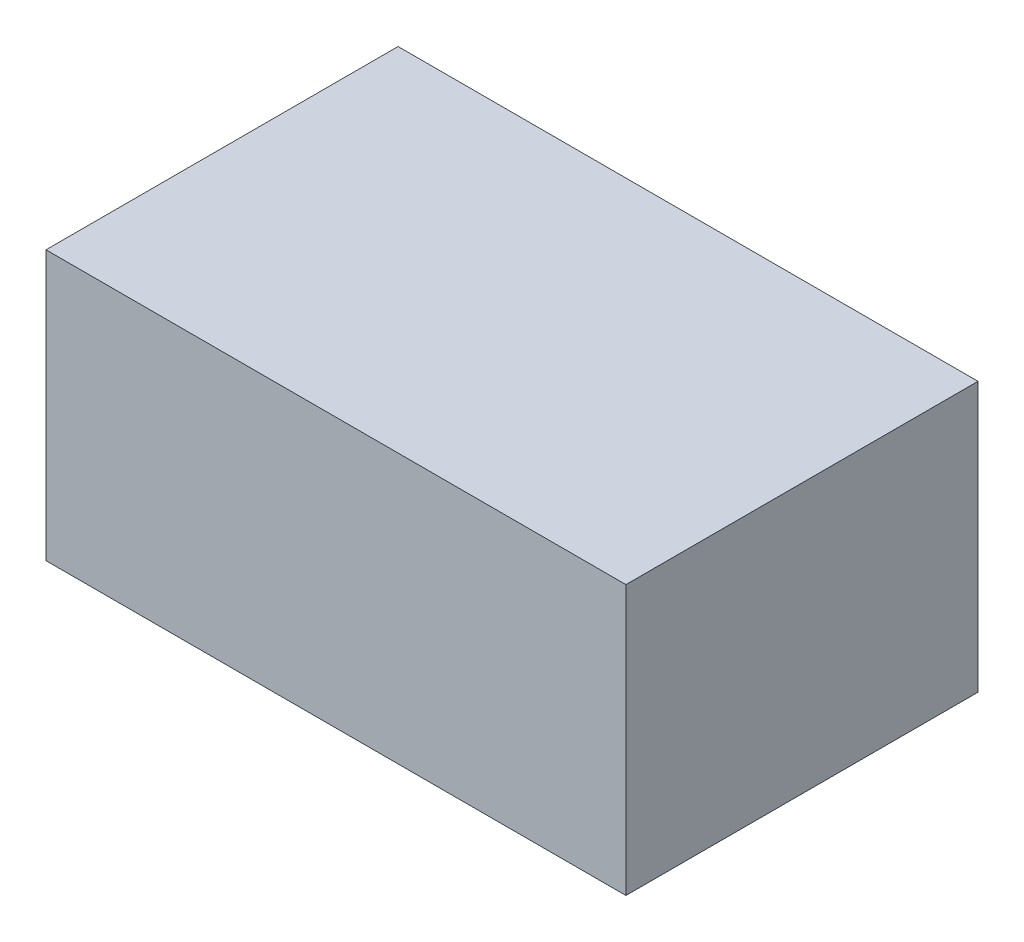
from build123d import *

# Parameters (mm, degrees)
SKETCH1_W           = 71.12
SKETCH1_H           = 43.18
BOSS_EXTRUDE1_DEPTH = 16.51


with BuildPart() as part:
    # Sketch1 → Boss-Extrude1 (new body, symmetric)
    with BuildSketch(Plane(origin=(0, 0, 0), x_dir=(1, 0, 0), z_dir=(0, 1, 0))):
        Rectangle(SKETCH1_W, SKETCH1_H)
    extrude(amount=BOSS_EXTRUDE1_DEPTH, both=True)


solid = part.part
